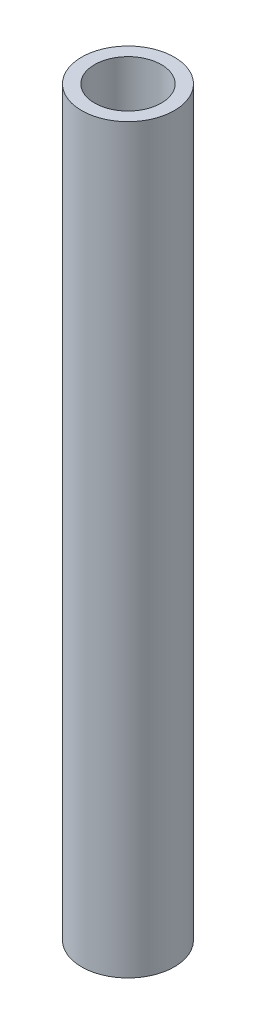
from build123d import *

# Parameters (mm, degrees)
SKETCH1_R           = 3.175
SKETCH1_R_2         = 2.286
BOSS_EXTRUDE1_DEPTH = 50.8


with BuildPart() as part:
    # Sketch1 → Boss-Extrude1 (new body)
    with BuildSketch(Plane(origin=(0, 0, 0), x_dir=(1, 0, 0), z_dir=(0, 1, 0))):
        Circle(SKETCH1_R)
        Circle(SKETCH1_R_2, mode=Mode.SUBTRACT)
    extrude(amount=BOSS_EXTRUDE1_DEPTH)


solid = part.part
